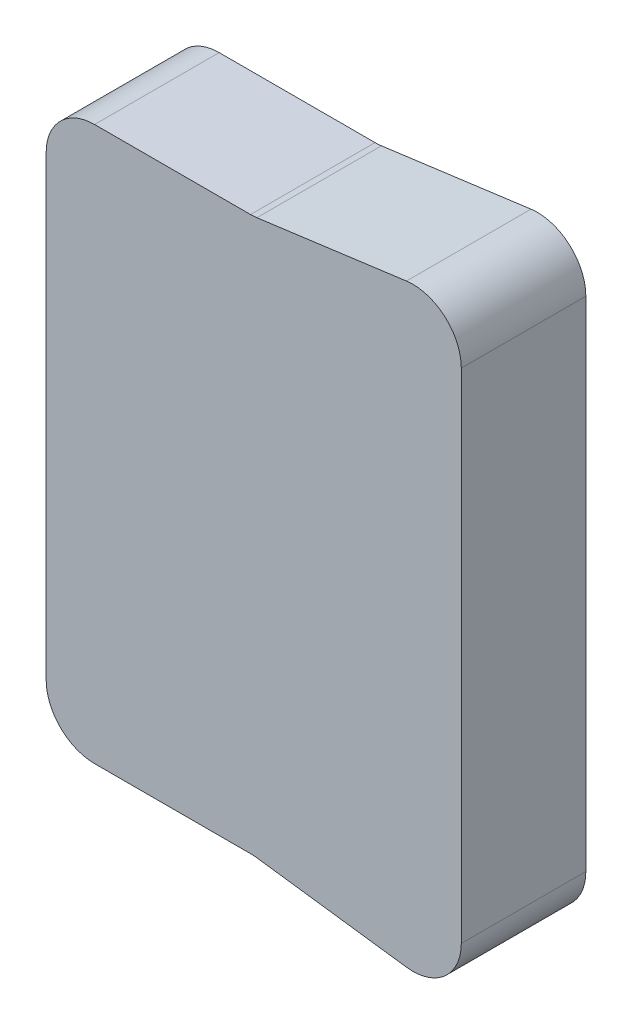
from build123d import *

# Parameters (mm, degrees)
BOSS_EXTRUDE1_DEPTH = 18
FILLET1_R           = 7


with BuildPart() as part:
    # Sketch1 → Boss-Extrude1 (new body)
    with BuildSketch(Plane.XY):
        Polygon((0, 80), (0, 0), (30, 0), (60, -4), (60, 84), (30, 80), align=None)
    extrude(amount=BOSS_EXTRUDE1_DEPTH)

    # Fillet1
    fillet1_edges = [part.edges().sort_by_distance(p)[0] for p in [
        (0, 80, 9),
        (30, 80, 9),
        (60, 84, 9),
        (60, -4, 9),
        (30, 0, 9),
        (0, 0, 9),
    ]]
    fillet(fillet1_edges, radius=FILLET1_R)


solid = part.part
